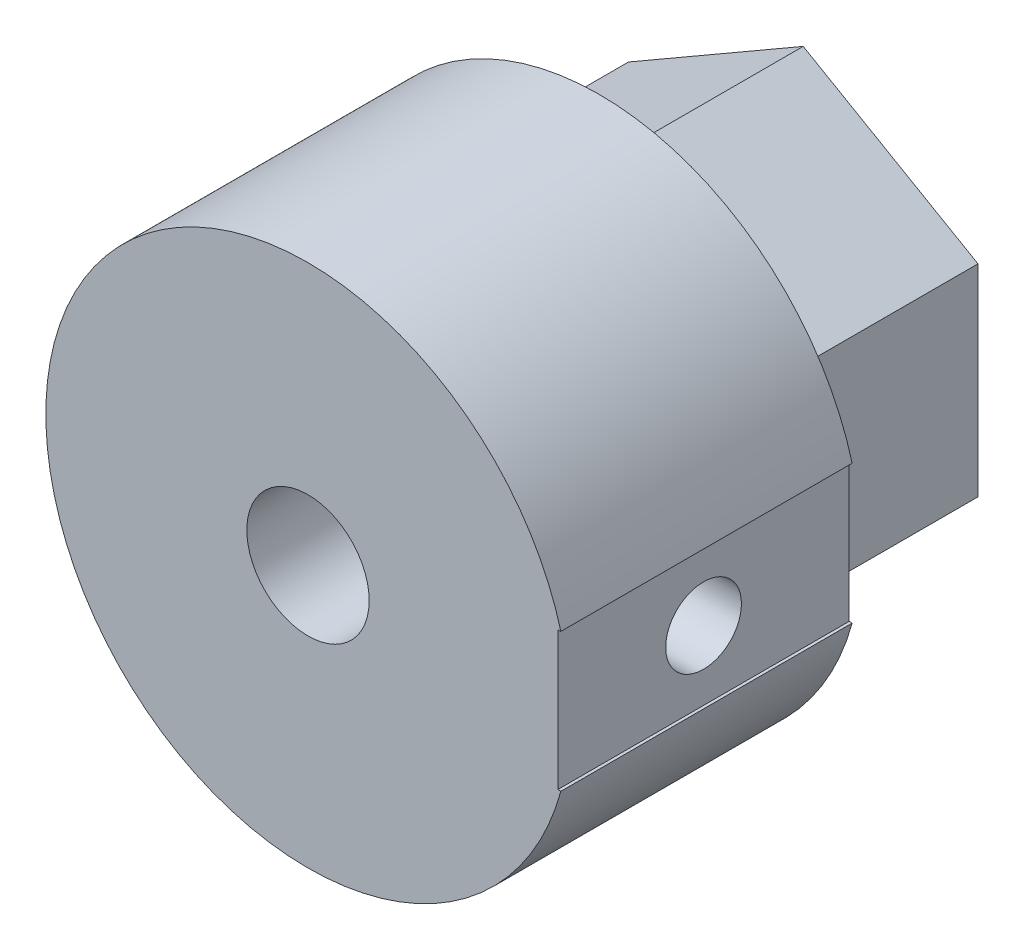
from build123d import *

# Parameters (mm, degrees)
BOSS_EXTRU_1_DEPTH      = 17
ESQUISSE2_R             = 1.3
ENL_V_MAT_EXTRU_1_DEPTH = 17
ESQUISSE3_R             = 9
ESQUISSE3_R_2           = 1.3
BOSS_EXTRU_2_DEPTH      = 10
ESQUISSE4_W             = 0.84262724
ESQUISSE4_H             = 4.751474998
ENL_V_MAT_EXTRU_2_DEPTH = 12
ESQUISSE5_R             = 1.3
ENL_V_MAT_EXTRU_3_DEPTH = 27
ESQUISSE6_R             = 2.1
ENL_V_MAT_EXTRU_4_DEPTH = 10


with BuildPart() as part:
    # Esquisse1 → Boss.-Extru.1 (new body)
    with BuildSketch(Plane.XY):
        Polygon((6, 3.464101615), (0, 6.92820323), (-6, 3.464101615), (-6, -3.464101615), (0, -6.92820323), (6, -3.464101615), align=None)
    extrude(amount=BOSS_EXTRU_1_DEPTH)

    # Esquisse2 → Enlèv. mat.-Extru.1 (cut)
    with BuildSketch(Plane.XY.offset(17)):
        Circle(ESQUISSE2_R)
    extrude(amount=-ENL_V_MAT_EXTRU_1_DEPTH, mode=Mode.SUBTRACT)

    # Esquisse3 → Boss.-Extru.2 (add)
    with BuildSketch(Plane.XY.offset(17)):
        Circle(ESQUISSE3_R)
        Circle(ESQUISSE3_R_2, mode=Mode.SUBTRACT)
    extrude(amount=-BOSS_EXTRU_2_DEPTH)

    # Esquisse4 → Enlèv. mat.-Extru.2 (cut)
    with BuildSketch(Plane.XY.offset(17)):
        with Locations((9, 0)):
            Rectangle(ESQUISSE4_W, ESQUISSE4_H)
    extrude(amount=-ENL_V_MAT_EXTRU_2_DEPTH, mode=Mode.SUBTRACT)

    # Esquisse5 → Enlèv. mat.-Extru.3 (cut)
    with BuildSketch(Plane(origin=(8.57868638, 0, 0), x_dir=(0, 0, -1), z_dir=(1, 0, 0))):
        with Locations((-12, 0)):
            Circle(ESQUISSE5_R)
    extrude(amount=-ENL_V_MAT_EXTRU_3_DEPTH, mode=Mode.SUBTRACT)

    # Esquisse6 → Enlèv. mat.-Extru.4 (cut)
    with BuildSketch(Plane.XY.offset(17)):
        Circle(ESQUISSE6_R)
    extrude(amount=-ENL_V_MAT_EXTRU_4_DEPTH, mode=Mode.SUBTRACT)


solid = part.part
